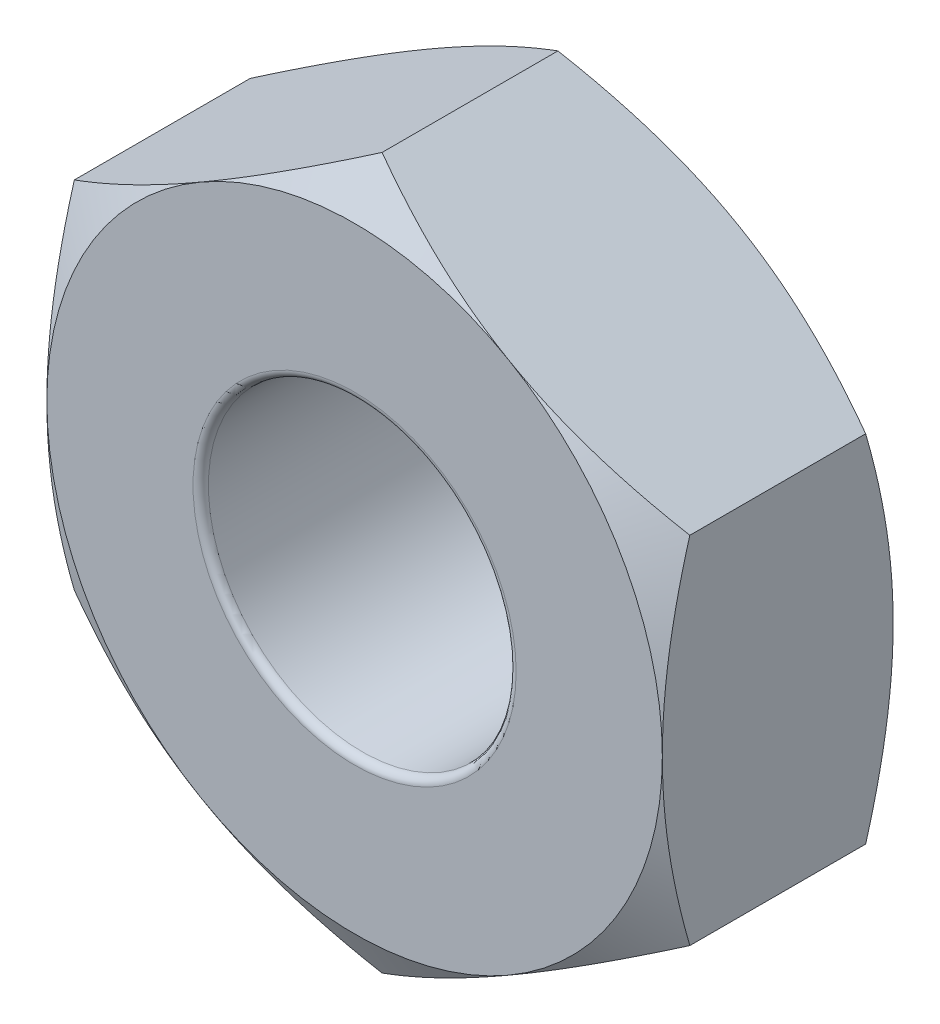
from build123d import *

# Parameters (mm, degrees)
SKETCH1_R           = 1
BOSS_EXTRUDE1_DEPTH = 1.5
SKETCH2_OUTSIDE_W   = 14.186
SKETCH2_OUTSIDE_H   = 14.804
SKETCH2_OUTSIDE_R   = 2
CUT_EXTRUDE1_DEPTH  = 2
CUT_EXTRUDE1_TAPER  = 60
SKETCH3_OUTSIDE_W   = 14.186
SKETCH3_OUTSIDE_H   = 14.804
SKETCH3_OUTSIDE_R   = 2
CUT_EXTRUDE2_DEPTH  = 2
CUT_EXTRUDE2_TAPER  = 60
FILLET1_R           = 0.05


with BuildPart() as part:
    # Sketch1 → Boss-Extrude1 (new body)
    with BuildSketch(Plane.XY):
        Polygon((0, -2.309401077), (2, -1.154700538), (2, 1.154700538), (0, 2.309401077), (-2, 1.154700538), (-2, -1.154700538), align=None)
        Circle(SKETCH1_R, mode=Mode.SUBTRACT)
    extrude(amount=BOSS_EXTRUDE1_DEPTH)

    # Sketch2 outside → Cut-Extrude1 (cut)
    with BuildSketch(Plane.XY.offset(1.5)):
        Rectangle(SKETCH2_OUTSIDE_W, SKETCH2_OUTSIDE_H)
        Circle(SKETCH2_OUTSIDE_R, mode=Mode.SUBTRACT)
    extrude(amount=-CUT_EXTRUDE1_DEPTH, taper=CUT_EXTRUDE1_TAPER, mode=Mode.SUBTRACT)

    # Sketch3 outside → Cut-Extrude2 (cut)
    with BuildSketch(Plane(origin=(0, 0, 0), x_dir=(-1, 0, 0), z_dir=(0, 0, -1))):
        Rectangle(SKETCH3_OUTSIDE_W, SKETCH3_OUTSIDE_H)
        Circle(SKETCH3_OUTSIDE_R, mode=Mode.SUBTRACT)
    extrude(amount=-CUT_EXTRUDE2_DEPTH, taper=CUT_EXTRUDE2_TAPER, mode=Mode.SUBTRACT)

    # Fillet1
    fillet1_edges = [part.edges().sort_by_distance(p)[0] for p in [
        (-1, 0, 0),
        (-1, 0, 1.5),
    ]]
    fillet(fillet1_edges, radius=FILLET1_R)


solid = part.part
